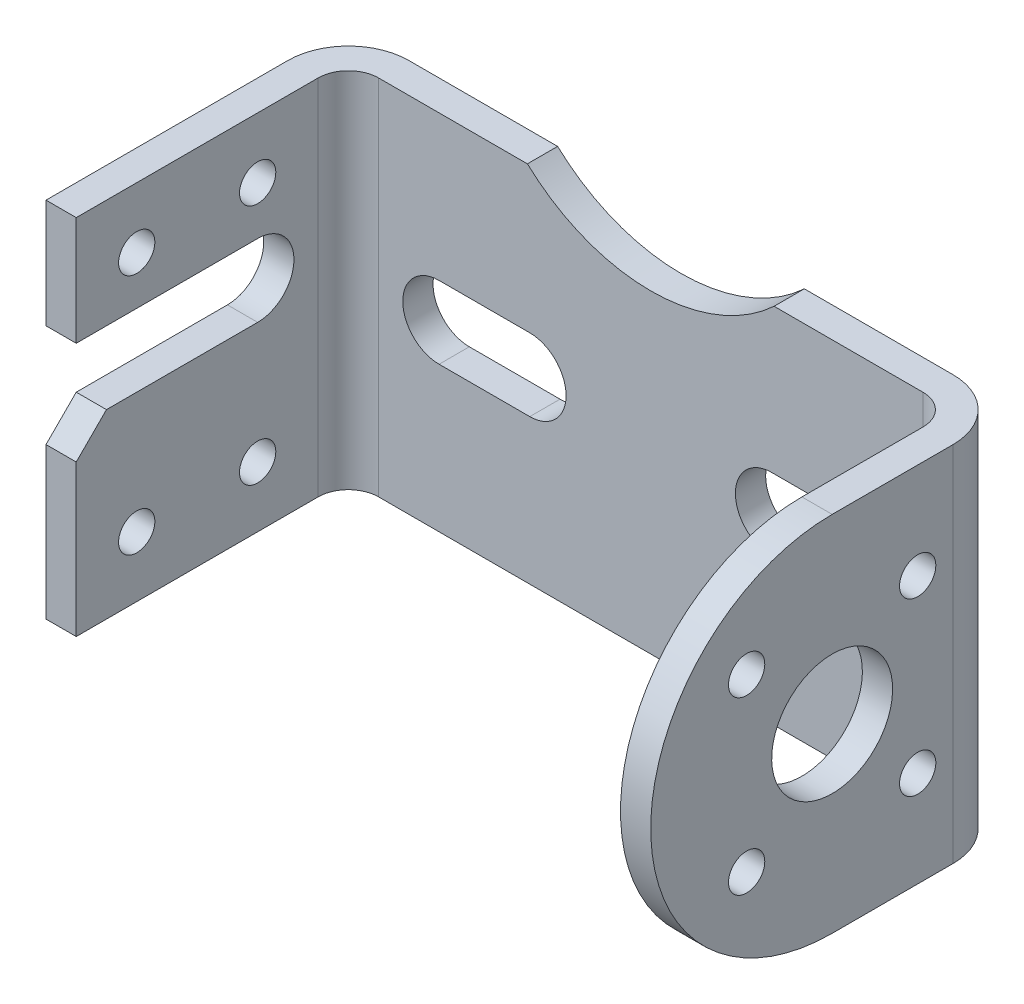
from build123d import *

# Parameters (mm, degrees)
SKETCH1_W           = 110
SKETCH1_H           = 60
BOSS_EXTRUDE1_DEPTH = 50
SKETCH2_W           = 100
SKETCH2_H           = 60
CUT_EXTRUDE1_DEPTH  = 45
FILLET1_R           = 5
FILLET2_R           = 10
SKETCH3_R           = 30
CUT_EXTRUDE2_DEPTH  = 6
CUT_EXTRUDE3_DEPTH  = 6
CUT_EXTRUDE4_REACH  = 112
CUT_EXTRUDE5_REACH  = 112
SKETCH6_R           = 3
BOSS_EXTRUDE2_DEPTH = 5
CUT_EXTRUDE6_REACH  = 112
CUT_EXTRUDE9_REACH  = 112
SKETCH10_R          = 10
SKETCH10_R_2        = 3
CHAMFER1_SIZE       = 5


with BuildPart() as part:
    # Sketch1 → Boss-Extrude1 (new body)
    with BuildSketch(Plane.XY):
        with Locations((55, -30)):
            Rectangle(SKETCH1_W, SKETCH1_H)
    extrude(amount=BOSS_EXTRUDE1_DEPTH)

    # Sketch2 → Cut-Extrude1 (cut)
    with BuildSketch(Plane.XY.offset(50)):
        with Locations((55, -30)):
            Rectangle(SKETCH2_W, SKETCH2_H)
    extrude(amount=-CUT_EXTRUDE1_DEPTH, mode=Mode.SUBTRACT)

    # Fillet1
    fillet1_edges = [part.edges().sort_by_distance(p)[0] for p in [
        (5, -30, 5),
        (105, -30, 5),
    ]]
    fillet(fillet1_edges, radius=FILLET1_R)

    # Fillet2
    fillet2_edges = [part.edges().sort_by_distance(p)[0] for p in [
        (110, -30, 0),
        (0, -30, 0),
    ]]
    fillet(fillet2_edges, radius=FILLET2_R)

    # Sketch3 → Cut-Extrude2 (cut, through all)
    with BuildSketch(Plane.XY.offset(5)):
        with Locations((55, 22)):
            Circle(SKETCH3_R)
    extrude(amount=-CUT_EXTRUDE2_DEPTH, mode=Mode.SUBTRACT)

    # Sketch4 → Cut-Extrude3 (cut, through all)
    with BuildSketch(Plane.XY.offset(5)):
        with BuildLine():
            Line((20, -24), (35, -24))
            ThreePointArc((35, -24), (41, -30), (35, -36))
            Line((35, -36), (20, -36))
            ThreePointArc((20, -36), (14, -30), (20, -24))
        make_face()
        with BuildLine():
            Line((90, -24), (75, -24))
            ThreePointArc((75, -24), (69, -30), (75, -36))
            Line((75, -36), (90, -36))
            ThreePointArc((90, -36), (96, -30), (90, -24))
        make_face()
    extrude(amount=-CUT_EXTRUDE3_DEPTH, mode=Mode.SUBTRACT)

    # Sketch5 → Cut-Extrude4 (cut, up to next)
    with BuildSketch(Plane.ZY, mode=Mode.PRIVATE) as cut_extrude4_sk1:
        with BuildLine():
            Line((60, -30), (20, -30))
            ThreePointArc((20, -30), (14, -24), (20, -18))
            Line((20, -18), (60, -18))
            ThreePointArc((60, -18), (66, -24), (60, -30))
        make_face()
    cut_extrude4_tool1 = extrude(cut_extrude4_sk1.sketch, amount=-CUT_EXTRUDE4_REACH, mode=Mode.PRIVATE) & part.part
    add(cut_extrude4_tool1.solids().sort_by_distance((0, -24, 40))[0], mode=Mode.SUBTRACT)

    # Sketch6 → Cut-Extrude5 (cut, up to next)
    with BuildSketch(Plane.ZY, mode=Mode.PRIVATE) as cut_extrude5_sk1:
        with Locations((20, -10)):
            Circle(SKETCH6_R)
    cut_extrude5_tool1 = extrude(cut_extrude5_sk1.sketch, amount=-CUT_EXTRUDE5_REACH, mode=Mode.PRIVATE) & part.part
    add(cut_extrude5_tool1.solids().sort_by_distance((0, -10, 20))[0], mode=Mode.SUBTRACT)
    # Sketch6 → Cut-Extrude5 (cut, up to next)
    with BuildSketch(Plane.ZY, mode=Mode.PRIVATE) as cut_extrude5_sk2:
        with Locations((40, -10)):
            Circle(SKETCH6_R)
    cut_extrude5_tool2 = extrude(cut_extrude5_sk2.sketch, amount=-CUT_EXTRUDE5_REACH, mode=Mode.PRIVATE) & part.part
    add(cut_extrude5_tool2.solids().sort_by_distance((0, -10, 40))[0], mode=Mode.SUBTRACT)
    # Sketch6 → Cut-Extrude5 (cut, up to next)
    with BuildSketch(Plane.ZY, mode=Mode.PRIVATE) as cut_extrude5_sk3:
        with Locations((40, -50)):
            Circle(SKETCH6_R)
    cut_extrude5_tool3 = extrude(cut_extrude5_sk3.sketch, amount=-CUT_EXTRUDE5_REACH, mode=Mode.PRIVATE) & part.part
    add(cut_extrude5_tool3.solids().sort_by_distance((0, -50, 40))[0], mode=Mode.SUBTRACT)
    # Sketch6 → Cut-Extrude5 (cut, up to next)
    with BuildSketch(Plane.ZY, mode=Mode.PRIVATE) as cut_extrude5_sk4:
        with Locations((20, -50)):
            Circle(SKETCH6_R)
    cut_extrude5_tool4 = extrude(cut_extrude5_sk4.sketch, amount=-CUT_EXTRUDE5_REACH, mode=Mode.PRIVATE) & part.part
    add(cut_extrude5_tool4.solids().sort_by_distance((0, -50, 20))[0], mode=Mode.SUBTRACT)

    # Sketch8 → Boss-Extrude2 (add)
    with BuildSketch(Plane(origin=(110, 0, 0), x_dir=(0, 0, -1), z_dir=(1, 0, 0))):
        with BuildLine():
            Line((-10, -7.639320225), (-10, -52.360679775))
            ThreePointArc((-10, -52.360679775), (-60, -30), (-10, -7.639320225))
        make_face()
    extrude(amount=-BOSS_EXTRUDE2_DEPTH)

    # Sketch9 → Cut-Extrude6 (cut, up to next)
    with BuildSketch(Plane(origin=(110, 0, 0), x_dir=(0, 0, -1), z_dir=(1, 0, 0)), mode=Mode.PRIVATE) as cut_extrude6_sk1:
        with BuildLine():
            Line((-50, -7.639320225), (-50, 0))
            Line((-50, 0), (-30, 0))
            ThreePointArc((-30, 0), (-40.704662693, -1.974829231), (-50, -7.639320225))
        make_face()
    cut_extrude6_tool1 = extrude(cut_extrude6_sk1.sketch, amount=-CUT_EXTRUDE6_REACH, mode=Mode.PRIVATE) & part.part
    add(cut_extrude6_tool1.solids().sort_by_distance((110, -2.231338, 45.13628))[0], mode=Mode.SUBTRACT)
    # Sketch9 → Cut-Extrude6 (cut, up to next)
    with BuildSketch(Plane(origin=(110, 0, 0), x_dir=(0, 0, -1), z_dir=(1, 0, 0)), mode=Mode.PRIVATE) as cut_extrude6_sk2:
        with BuildLine():
            Line((-50, -60), (-30, -60))
            ThreePointArc((-30, -60), (-40.704662693, -58.025170769), (-50, -52.360679775))
            Line((-50, -52.360679775), (-50, -60))
        make_face()
    cut_extrude6_tool2 = extrude(cut_extrude6_sk2.sketch, amount=-CUT_EXTRUDE6_REACH, mode=Mode.PRIVATE) & part.part
    add(cut_extrude6_tool2.solids().sort_by_distance((110, -57.768662, 45.13628))[0], mode=Mode.SUBTRACT)

    # Sketch10 → Cut-Extrude9 (cut, up to next)
    with BuildSketch(Plane(origin=(110, 0, 0), x_dir=(0, 0, -1), z_dir=(1, 0, 0)), mode=Mode.PRIVATE) as cut_extrude9_sk1:
        with Locations((-30, -30)):
            Circle(SKETCH10_R)
    cut_extrude9_tool1 = extrude(cut_extrude9_sk1.sketch, amount=-CUT_EXTRUDE9_REACH, mode=Mode.PRIVATE) & part.part
    add(cut_extrude9_tool1.solids().sort_by_distance((110, -30, 30))[0], mode=Mode.SUBTRACT)
    # Sketch10 → Cut-Extrude9 (cut, up to next)
    with BuildSketch(Plane(origin=(110, 0, 0), x_dir=(0, 0, -1), z_dir=(1, 0, 0)), mode=Mode.PRIVATE) as cut_extrude9_sk2:
        with Locations((-44.142135624, -15.857864376)):
            Circle(SKETCH10_R_2)
    cut_extrude9_tool2 = extrude(cut_extrude9_sk2.sketch, amount=-CUT_EXTRUDE9_REACH, mode=Mode.PRIVATE) & part.part
    add(cut_extrude9_tool2.solids().sort_by_distance((110, -15.857864, 44.142136))[0], mode=Mode.SUBTRACT)
    # Sketch10 → Cut-Extrude9 (cut, up to next)
    with BuildSketch(Plane(origin=(110, 0, 0), x_dir=(0, 0, -1), z_dir=(1, 0, 0)), mode=Mode.PRIVATE) as cut_extrude9_sk3:
        with Locations((-15.857864376, -15.857864376)):
            Circle(SKETCH10_R_2)
    cut_extrude9_tool3 = extrude(cut_extrude9_sk3.sketch, amount=-CUT_EXTRUDE9_REACH, mode=Mode.PRIVATE) & part.part
    add(cut_extrude9_tool3.solids().sort_by_distance((110, -15.857864, 15.857864))[0], mode=Mode.SUBTRACT)
    # Sketch10 → Cut-Extrude9 (cut, up to next)
    with BuildSketch(Plane(origin=(110, 0, 0), x_dir=(0, 0, -1), z_dir=(1, 0, 0)), mode=Mode.PRIVATE) as cut_extrude9_sk4:
        with Locations((-15.857864376, -44.142135624)):
            Circle(SKETCH10_R_2)
    cut_extrude9_tool4 = extrude(cut_extrude9_sk4.sketch, amount=-CUT_EXTRUDE9_REACH, mode=Mode.PRIVATE) & part.part
    add(cut_extrude9_tool4.solids().sort_by_distance((110, -44.142136, 15.857864))[0], mode=Mode.SUBTRACT)
    # Sketch10 → Cut-Extrude9 (cut, up to next)
    with BuildSketch(Plane(origin=(110, 0, 0), x_dir=(0, 0, -1), z_dir=(1, 0, 0)), mode=Mode.PRIVATE) as cut_extrude9_sk5:
        with Locations((-44.142135624, -44.142135624)):
            Circle(SKETCH10_R_2)
    cut_extrude9_tool5 = extrude(cut_extrude9_sk5.sketch, amount=-CUT_EXTRUDE9_REACH, mode=Mode.PRIVATE) & part.part
    add(cut_extrude9_tool5.solids().sort_by_distance((110, -44.142136, 44.142136))[0], mode=Mode.SUBTRACT)

    # Chamfer1
    chamfer1_edges = [part.edges().sort_by_distance(p)[0] for p in [
        (2.5, -30, 50),
    ]]
    chamfer(chamfer1_edges, length=CHAMFER1_SIZE)


solid = part.part
